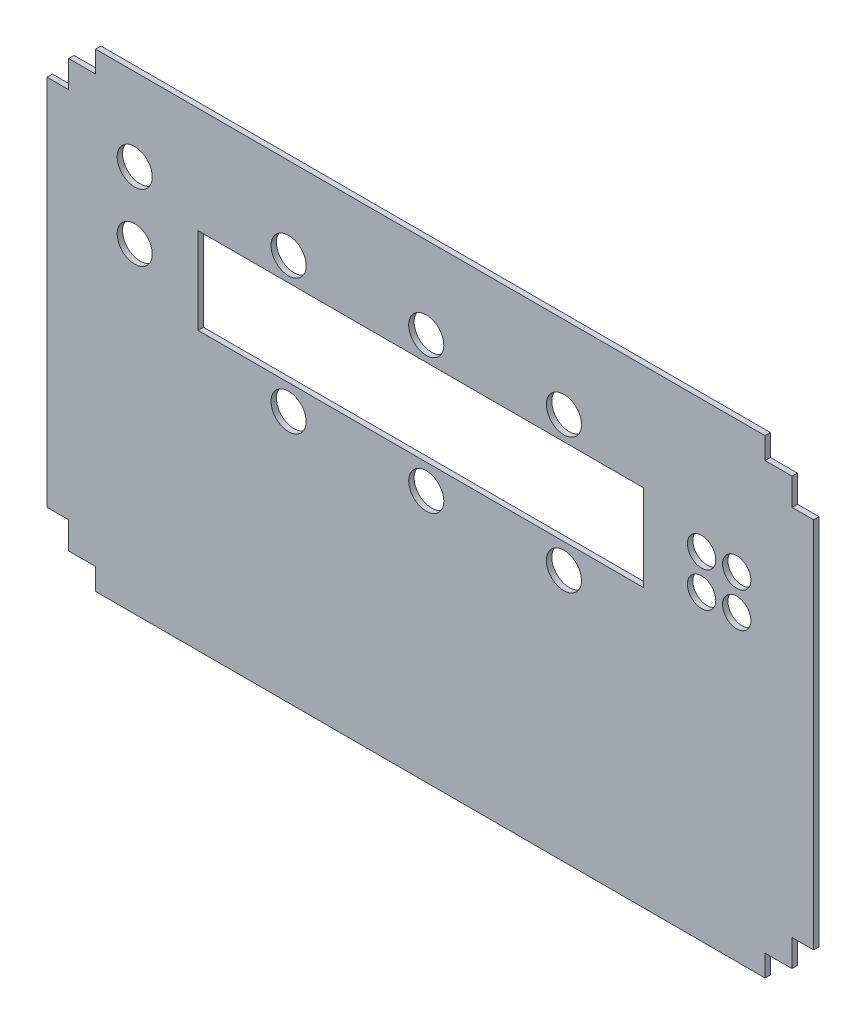
from build123d import *

# Parameters (mm, degrees)
MODEL_R                  = 6.5
MODEL_R_2                = 5.25
MODEL_W                  = 165
MODEL_H                  = 32
RESSALTO_EXTRUS_O1_DEPTH = 2


with BuildPart() as part:
    # Model → Ressalto-extrusão1 (new body)
    with BuildSketch(Plane.XY):
        Polygon((270.074227849, 25.427113901), (280.074227849, 25.427113901), (280.074227849, 35.427113901), (288.074227849, 35.427113901), (288.074227849, 173.427113901), (280.074227849, 173.427113901), (280.074227849, 183.427113901), (270.074227849, 183.427113901), (270.074227849, 191.427113901), (22.074227849, 191.427113901), (22.074227849, 183.427113901), (12.074227849, 183.427113901), (12.074227849, 173.427113901), (4.074227849, 173.427113901), (4.074227849, 35.427113901), (12.074227849, 35.427113901), (12.074227849, 25.427113901), (22.074227849, 25.427113901), (22.074227849, 17.427113901), (270.074227849, 17.427113901), align=None)
        with Locations((36.574227849, 160.927113901)):
            Circle(MODEL_R, mode=Mode.SUBTRACT)
        with Locations((36.574227849, 136.177113901)):
            Circle(MODEL_R, mode=Mode.SUBTRACT)
        with Locations((93.574227849, 110.927113901)):
            Circle(MODEL_R, mode=Mode.SUBTRACT)
        with Locations((144.574227849, 110.927113901)):
            Circle(MODEL_R, mode=Mode.SUBTRACT)
        with Locations((195.574227849, 110.927113901)):
            Circle(MODEL_R, mode=Mode.SUBTRACT)
        with Locations((195.574227849, 160.927113901)):
            Circle(MODEL_R, mode=Mode.SUBTRACT)
        with Locations((144.574227849, 160.927113901)):
            Circle(MODEL_R, mode=Mode.SUBTRACT)
        with Locations((93.574227849, 160.927113901)):
            Circle(MODEL_R, mode=Mode.SUBTRACT)
        with Locations((246.574227849, 142.427113901)):
            Circle(MODEL_R_2, mode=Mode.SUBTRACT)
        with Locations((259.574227849, 142.427113901)):
            Circle(MODEL_R_2, mode=Mode.SUBTRACT)
        with Locations((259.574227849, 129.427113901)):
            Circle(MODEL_R_2, mode=Mode.SUBTRACT)
        with Locations((246.574227849, 129.427113901)):
            Circle(MODEL_R_2, mode=Mode.SUBTRACT)
        with Locations((142.574227849, 136.177113901)):
            Rectangle(MODEL_W, MODEL_H, mode=Mode.SUBTRACT)
    extrude(amount=RESSALTO_EXTRUS_O1_DEPTH)


solid = part.part
